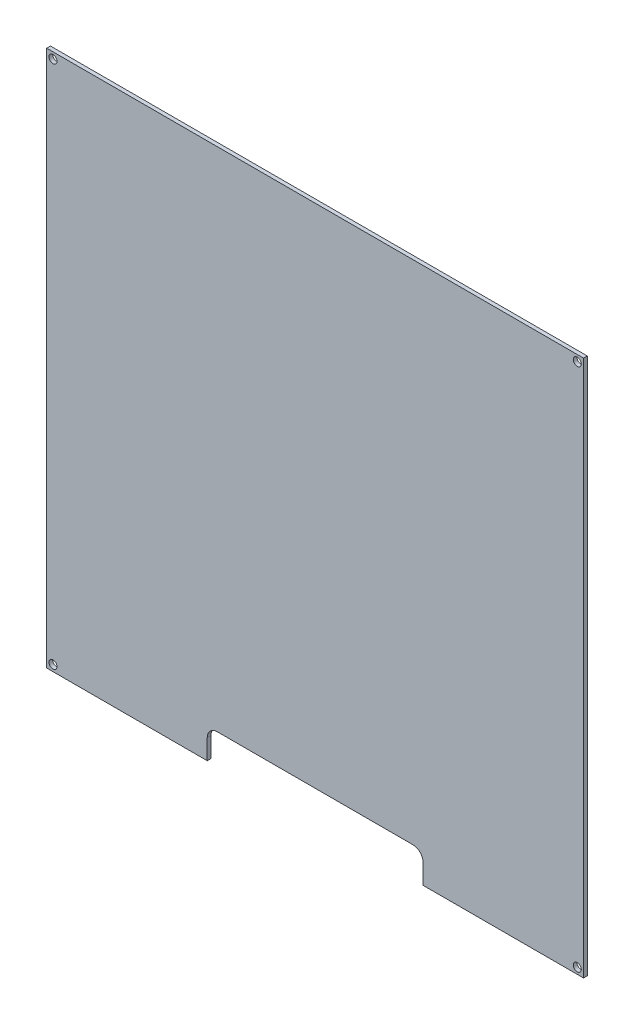
from build123d import *

# Parameters (mm, degrees)
SKETCH1_W           = 214
SKETCH1_H           = 214
SKETCH1_R           = 1.6
BOSS_EXTRUDE1_DEPTH = 1.5
SKETCH2_W           = 86
SKETCH2_H           = 12
CUT_EXTRUDE1_DEPTH  = 2.5
FILLET1_R           = 4


with BuildPart() as part:
    # Sketch1 → Boss-Extrude1 (new body)
    with BuildSketch(Plane.XY):
        Rectangle(SKETCH1_W, SKETCH1_H)
        with Locations((-104.5, 104.5)):
            Circle(SKETCH1_R, mode=Mode.SUBTRACT)
        with Locations((104.5, 104.5)):
            Circle(SKETCH1_R, mode=Mode.SUBTRACT)
        with Locations((0, -104.5)):
            Circle(SKETCH1_R, mode=Mode.SUBTRACT)
        with Locations((104.5, -104.5)):
            Circle(SKETCH1_R, mode=Mode.SUBTRACT)
        with Locations((-104.5, -104.5)):
            Circle(SKETCH1_R, mode=Mode.SUBTRACT)
    extrude(amount=BOSS_EXTRUDE1_DEPTH)

    # Sketch2 → Cut-Extrude1 (cut, through all)
    with BuildSketch(Plane.XY.offset(1.5)):
        with Locations((0, -101)):
            Rectangle(SKETCH2_W, SKETCH2_H)
    extrude(amount=-CUT_EXTRUDE1_DEPTH, mode=Mode.SUBTRACT)

    # Fillet1
    fillet1_edges = [part.edges().sort_by_distance(p)[0] for p in [
        (-43, -95, 0.75),
        (43, -95, 0.75),
    ]]
    fillet(fillet1_edges, radius=FILLET1_R)


solid = part.part
